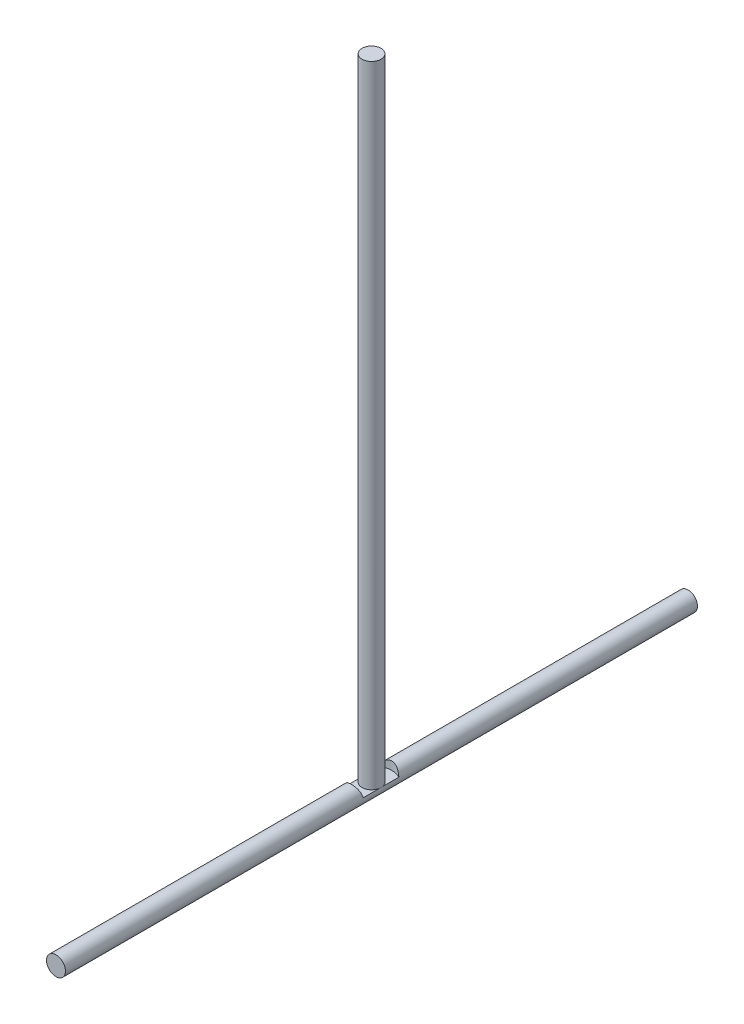
from build123d import *

# Parameters (mm, degrees)
SKETCH1_R           = 7.5
BOSS_EXTRUDE1_DEPTH = 500
SKETCH2_R           = 16
CUT_EXTRUDE1_DEPTH  = 15
SKETCH4_R           = 7.5
BOSS_EXTRUDE2_DEPTH = 499


with BuildPart() as part:
    # Sketch1 → Boss-Extrude1 (new body)
    with BuildSketch(Plane.XY):
        Circle(SKETCH1_R)
    extrude(amount=BOSS_EXTRUDE1_DEPTH)

    # Sketch2 → Cut-Extrude1 (cut)
    with BuildSketch(Plane(origin=(0, 16, 0), x_dir=(1, 0, 0), z_dir=(0, 1, 0))):
        with Locations((0, -250.362407272)):
            Circle(SKETCH2_R)
    extrude(amount=-CUT_EXTRUDE1_DEPTH, mode=Mode.SUBTRACT)

    # Sketch4 → Boss-Extrude2 (add)
    with BuildSketch(Plane(origin=(0, 1, 0), x_dir=(1, 0, 0), z_dir=(0, 1, 0))):
        with Locations((0, -250.362407272)):
            Circle(SKETCH4_R)
    extrude(amount=BOSS_EXTRUDE2_DEPTH)


solid = part.part
